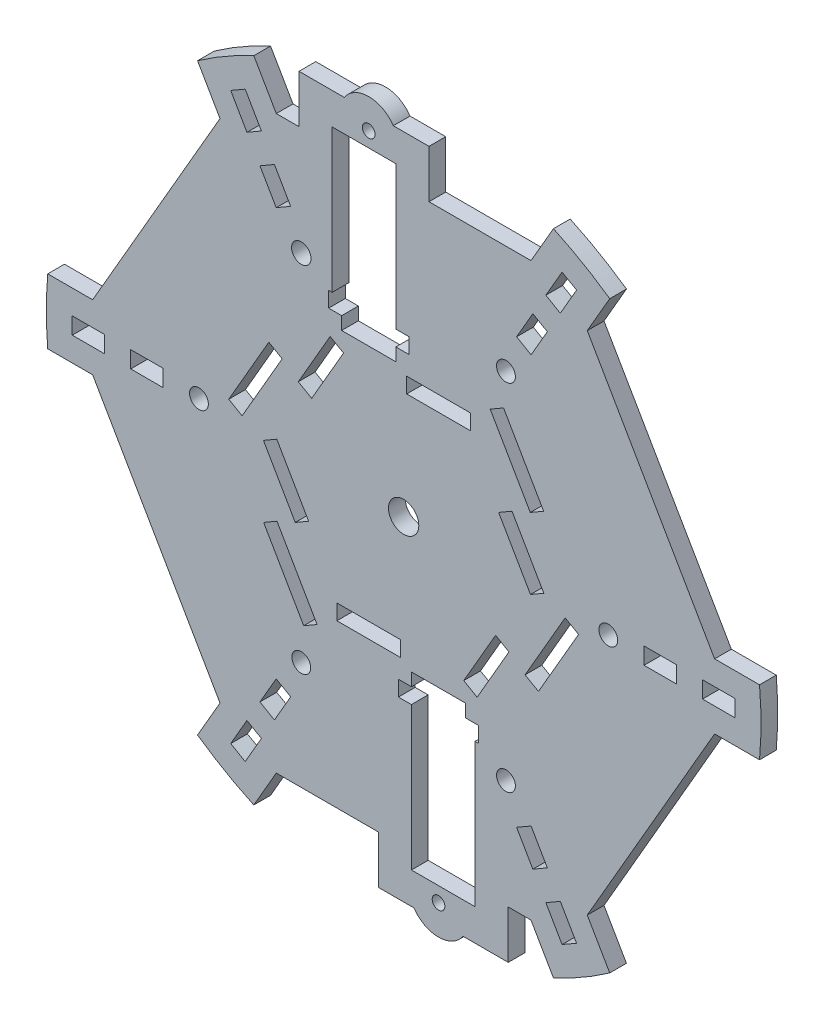
from build123d import *

# Parameters (mm, degrees)
MODEL_R             = 2.9
MODEL_R_2           = 3
MODEL_R_3           = 4.665
MODEL_R_4           = 1.95
MODEL_W             = 10
MODEL_H             = 5.15
MODEL_W_2           = 19.6
MODEL_H_2           = 4.75
BOSS_EXTRUDE1_DEPTH = 5.15


with BuildPart() as part:
    # Model → Boss-Extrude1 (new body)
    with BuildSketch(Plane.XY):
        with BuildLine():
            Line((-56.520735382, 77.896206612), (-95.720735382, 9.999814955))
            Line((-95.720735382, 9.999814955), (-109.544528393, 9.999814955))
            ThreePointArc((-109.544528393, 9.999814955), (-110, -0.000331846), (-109.544468057, -10.000475899))
            Line((-109.544468057, -10.000475899), (-95.72019722, -10.000475899))
            Line((-95.72019722, -10.000475899), (-56.52019722, -77.896867556))
            Line((-56.52019722, -77.896867556), (-63.432093724, -89.868623478))
            ThreePointArc((-63.432093724, -89.868623478), (-54.999779481, -95.262921733), (-46.112001713, -99.868329805))
            Line((-46.112001713, -99.868329805), (-39.2, -87.896391657))
            Line((-39.2, -87.896391657), (-7.8, -87.896391657))
            Line((-7.8, -87.896391657), (-7.8, -102.664454178))
            Line((-7.8, -102.664454178), (3.176931839, -102.664454178))
            ThreePointArc((3.176931839, -102.664454178), (10.74, -106.664454178), (18.303068161, -102.664454178))
            Line((18.303068161, -102.664454178), (32.2, -102.664454178))
            Line((32.2, -102.664454178), (32.2, -87.896391657))
            Line((32.2, -87.896391657), (39.2, -87.896391657))
            Line((39.2, -87.896391657), (46.112001713, -99.868329805))
            ThreePointArc((46.112001713, -99.868329805), (54.999874175, -95.262867061), (63.432272389, -89.86849737))
            Line((63.432272389, -89.86849737), (56.520280769, -77.896576702))
            Line((56.520280769, -77.896576702), (95.720280769, -10.000185045))
            Line((95.720280769, -10.000185045), (109.544494609, -10.000185045))
            ThreePointArc((109.544494609, -10.000185045), (109.999999999, -0.000331846), (109.544554943, 9.999524101))
            Line((109.544554943, 9.999524101), (95.720818931, 9.999524101))
            Line((95.720818931, 9.999524101), (56.520818931, 77.895915758))
            Line((56.520818931, 77.895915758), (63.432925851, 89.868036131))
            ThreePointArc((63.432925851, 89.868036131), (55.000220519, 95.262667099), (46.112001713, 99.868329805))
            Line((46.112001713, 99.868329805), (39.2, 87.896391657))
            Line((39.2, 87.896391657), (7.8, 87.896391657))
            Line((7.8, 87.896391657), (7.8, 102.664454178))
            Line((7.8, 102.664454178), (-3.176931839, 102.664454178))
            ThreePointArc((-3.176931839, 102.664454178), (-10.74, 106.664454178), (-18.303068161, 102.664454178))
            Line((-18.303068161, 102.664454178), (-32.2, 102.664454178))
            Line((-32.2, 102.664454178), (-32.2, 87.896391657))
            Line((-32.2, 87.896391657), (-39.2, 87.896391657))
            Line((-39.2, 87.896391657), (-46.112001713, 99.868329805))
            ThreePointArc((-46.112001713, 99.868329805), (-55.000125824, 95.262721771), (-63.432747187, 89.86816224))
            Line((-63.432747187, 89.86816224), (-56.520735382, 77.896206612))
        make_face()
        with Locations((-63, 0)):
            Circle(MODEL_R, mode=Mode.SUBTRACT)
        with Locations((-31.5, -54.559600438)):
            Circle(MODEL_R, mode=Mode.SUBTRACT)
        with Locations((31.5, -54.559600438)):
            Circle(MODEL_R, mode=Mode.SUBTRACT)
        with Locations((63, 0)):
            Circle(MODEL_R, mode=Mode.SUBTRACT)
        with Locations((31.5, 54.559600438)):
            Circle(MODEL_R, mode=Mode.SUBTRACT)
        with Locations((-31.5, 54.559600438)):
            Circle(MODEL_R_2, mode=Mode.SUBTRACT)
        Circle(MODEL_R_3, mode=Mode.SUBTRACT)
        with Locations((10.74, -97.514454178)):
            Circle(MODEL_R_4, mode=Mode.SUBTRACT)
        with Locations((-10.74, 97.514454177)):
            Circle(MODEL_R_4, mode=Mode.SUBTRACT)
        with Locations((79, 0)):
            Rectangle(MODEL_W, MODEL_H, mode=Mode.SUBTRACT)
        with Locations((97, 0)):
            Rectangle(MODEL_W, MODEL_H, mode=Mode.SUBTRACT)
        Polygon((34.769984585, 65.37337988), (39.230015415, 62.79837988), (44.230015415, 71.458633918), (39.769984585, 74.033633918), align=None, mode=Mode.SUBTRACT)
        Polygon((43.769984585, 80.961837148), (48.230015415, 78.386837148), (53.230015415, 87.047091186), (48.769984585, 89.622091186), align=None, mode=Mode.SUBTRACT)
        Polygon((-48.230015415, 78.386837148), (-43.769984585, 80.961837148), (-48.769984585, 89.622091186), (-53.230015415, 87.047091186), align=None, mode=Mode.SUBTRACT)
        Polygon((-39.230015415, 62.79837988), (-34.769984585, 65.37337988), (-39.769984585, 74.033633918), (-44.230015415, 71.458633918), align=None, mode=Mode.SUBTRACT)
        with Locations((-79, 0)):
            Rectangle(MODEL_W, MODEL_H, mode=Mode.SUBTRACT)
        with Locations((-97, 0)):
            Rectangle(MODEL_W, MODEL_H, mode=Mode.SUBTRACT)
        Polygon((-34.769984585, -65.37337988), (-39.230015415, -62.79837988), (-44.230015415, -71.458633918), (-39.769984585, -74.033633918), align=None, mode=Mode.SUBTRACT)
        Polygon((-43.769984585, -80.961837148), (-48.230015415, -78.386837148), (-53.230015415, -87.047091186), (-48.769984585, -89.622091186), align=None, mode=Mode.SUBTRACT)
        Polygon((39.230015415, -62.79837988), (34.769984585, -65.37337988), (39.769984585, -74.033633918), (44.230015415, -71.458633918), align=None, mode=Mode.SUBTRACT)
        Polygon((48.230015415, -78.386837148), (43.769984585, -80.961837148), (48.769984585, -89.622091186), (53.230015415, -87.047091186), align=None, mode=Mode.SUBTRACT)
        Polygon((33.357314709, 18.17343612), (29.243694041, 15.79843612), (39.043694041, -1.175661794), (43.157314709, 1.199338206), align=None, mode=Mode.SUBTRACT)
        Polygon((32.417314709, -19.80156388), (28.303694041, -17.42656388), (18.503694041, -34.400661794), (22.617314709, -36.775661794), align=None, mode=Mode.SUBTRACT)
        with Locations((-10.74, -35.6)):
            Rectangle(MODEL_W_2, MODEL_H_2, mode=Mode.SUBTRACT)
        Polygon((-33.357314709, -18.17343612), (-29.243694041, -15.79843612), (-39.043694041, 1.175661794), (-43.157314709, -1.199338206), align=None, mode=Mode.SUBTRACT)
        Polygon((-32.417314709, 19.80156388), (-28.303694041, 17.42656388), (-18.503694041, 34.400661794), (-22.617314709, 36.775661794), align=None, mode=Mode.SUBTRACT)
        Polygon((38.982587357, 20.659086443), (43.096208025, 23.034086443), (30.756208025, 44.407593408), (26.642587357, 42.032593408), align=None, mode=Mode.SUBTRACT)
        Polygon((37.382587357, -23.430367735), (41.496208025, -25.805367735), (53.836208025, -4.431860769), (49.722587357, -2.056860769), align=None, mode=Mode.SUBTRACT)
        Polygon((2.4, -44.089454178), (-1.6, -44.089454178), (-1.6, -48.839454177), (2.4, -48.839454177), (2.4, -92.939454178), (22, -92.939454178), (22, -48.839454177), (23.08, -48.839454177), (23.08, -44.089454178), (19.08, -44.089454178), (19.08, -40.139454177), (2.4, -40.139454177), align=None, mode=Mode.SUBTRACT)
        Polygon((-38.982587357, -20.659086443), (-43.096208025, -23.034086443), (-30.756208025, -44.407593408), (-26.642587357, -42.032593408), align=None, mode=Mode.SUBTRACT)
        Polygon((-37.382587357, 23.430367735), (-41.496208025, 25.805367735), (-53.836208025, 4.431860769), (-49.722587357, 2.056860769), align=None, mode=Mode.SUBTRACT)
        with Locations((10.74, 35.6)):
            Rectangle(MODEL_W_2, MODEL_H_2, mode=Mode.SUBTRACT)
        Polygon((-2.4, 44.089454178), (1.6, 44.089454178), (1.6, 48.839454177), (-2.4, 48.839454177), (-2.4, 92.939454178), (-22, 92.939454178), (-22, 48.839454177), (-23.08, 48.839454177), (-23.08, 44.089454178), (-19.08, 44.089454178), (-19.08, 40.139454177), (-2.4, 40.139454177), align=None, mode=Mode.SUBTRACT)
    extrude(amount=BOSS_EXTRUDE1_DEPTH)


solid = part.part
